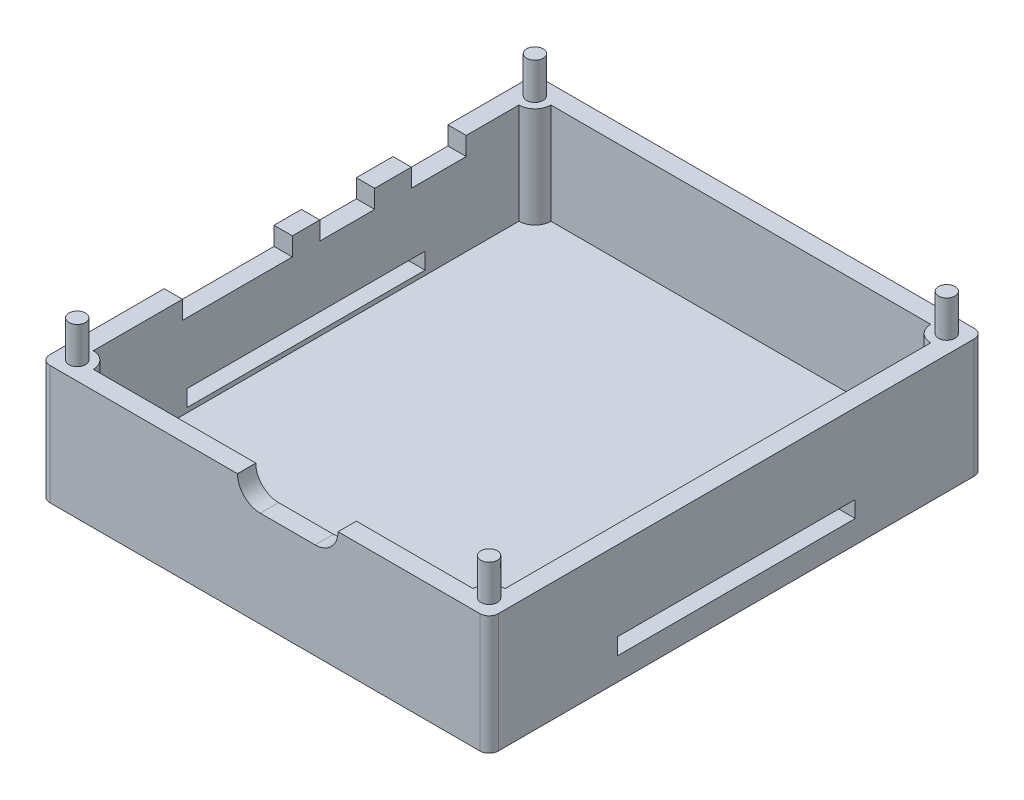
from build123d import *

# Parameters (mm, degrees)
SKETCH1_W             = 49
SKETCH1_H             = 54
BOSS_EXTRUDE1_DEPTH   = 2
SKETCH2_W             = 49
SKETCH2_H             = 54
SKETCH2_W_2           = 45
SKETCH2_H_2           = 50
EXTRUDE_THIN1_DEPTH   = 11
SKETCH7_W             = 6
SKETCH7_H             = 2
CUT_EXTRUDE1_DEPTH    = 2
SKETCH6_W             = 12
SKETCH6_H             = 2
CUT_EXTRUDE2_DEPTH    = 2
CUT_EXTRUDE3_DEPTH    = 2
SKETCH15_R            = 1.75
BOSS_EXTRUDE2_DEPTH   = 11
BOSS_EXTRUDE2_2_DEPTH = 11
BOSS_EXTRUDE2_3_DEPTH = 11
BOSS_EXTRUDE2_4_DEPTH = 11
SKETCH17_R            = 0.9
BOSS_EXTRUDE3_DEPTH   = 15
CUT_EXTRUDE4_DEPTH    = 49
FILLET1_R             = 1


with BuildPart() as part:
    # Sketch1 → Boss-Extrude1 (new body)
    with BuildSketch(Plane(origin=(0, 0, 0), x_dir=(1, 0, 0), z_dir=(0, 1, 0))):
        Rectangle(SKETCH1_W, SKETCH1_H)
    extrude(amount=BOSS_EXTRUDE1_DEPTH)

    # Sketch2 → Extrude-Thin1 (add)
    with BuildSketch(Plane(origin=(0, 2, 0), x_dir=(1, 0, 0), z_dir=(0, 1, 0))):
        Rectangle(SKETCH2_W, SKETCH2_H)
        Rectangle(SKETCH2_W_2, SKETCH2_H_2, mode=Mode.SUBTRACT)
    extrude(amount=EXTRUDE_THIN1_DEPTH)

    # Sketch7 → Cut-Extrude1 (cut)
    with BuildSketch(Plane.ZY.offset(24.5)):
        with Locations((-4.5, 12)):
            Rectangle(SKETCH7_W, SKETCH7_H)
        with Locations((-14.5, 12)):
            Rectangle(SKETCH7_W, SKETCH7_H)
    extrude(amount=-CUT_EXTRUDE1_DEPTH, mode=Mode.SUBTRACT)

    # Sketch6 → Cut-Extrude2 (cut)
    with BuildSketch(Plane.ZY.offset(24.5)):
        with Locations((7.5, 12)):
            Rectangle(SKETCH6_W, SKETCH6_H)
    extrude(amount=-CUT_EXTRUDE2_DEPTH, mode=Mode.SUBTRACT)

    # Sketch14 → Cut-Extrude3 (cut)
    with BuildSketch(Plane.XY.offset(27)):
        with BuildLine():
            Line((-0.5, 15.493238672), (5.5, 15.493238672))
            ThreePointArc((5.5, 15.493238672), (7.993238672, 13), (5.5, 10.506761328))
            Line((5.5, 10.506761328), (-0.5, 10.506761328))
            ThreePointArc((-0.5, 10.506761328), (-2.993238672, 13), (-0.5, 15.493238672))
        make_face()
    extrude(amount=-CUT_EXTRUDE3_DEPTH, mode=Mode.SUBTRACT)



with BuildPart() as body_2:
    # Sketch15 → Boss-Extrude2 (new body)
    with BuildSketch(Plane(origin=(0, 2, 0), x_dir=(1, 0, 0), z_dir=(0, 1, 0))):
        with Locations((-22.5, -25)):
            Circle(SKETCH15_R)
    extrude(amount=BOSS_EXTRUDE2_DEPTH)


with BuildPart() as body_3:
    # Sketch15 → Boss-Extrude2 2 (new body)
    with BuildSketch(Plane(origin=(0, 2, 0), x_dir=(1, 0, 0), z_dir=(0, 1, 0))):
        with Locations((-22.5, 25)):
            Circle(SKETCH15_R)
    extrude(amount=BOSS_EXTRUDE2_2_DEPTH)


with BuildPart() as body_4:
    # Sketch15 → Boss-Extrude2 3 (new body)
    with BuildSketch(Plane(origin=(0, 2, 0), x_dir=(1, 0, 0), z_dir=(0, 1, 0))):
        with Locations((22.5, 25)):
            Circle(SKETCH15_R)
    extrude(amount=BOSS_EXTRUDE2_3_DEPTH)


with BuildPart() as body_5:
    # Sketch15 → Boss-Extrude2 4 (new body)
    with BuildSketch(Plane(origin=(0, 2, 0), x_dir=(1, 0, 0), z_dir=(0, 1, 0))):
        with Locations((22.5, -25)):
            Circle(SKETCH15_R)
    extrude(amount=BOSS_EXTRUDE2_4_DEPTH)


with BuildPart() as part_1:
    add(part.part)

    add(body_2.part)  # Boss-Extrude3 merges body 2

    add(body_3.part)  # Boss-Extrude3 merges body 3

    add(body_4.part)  # Boss-Extrude3 merges body 4

    add(body_5.part)  # Boss-Extrude3 merges body 5
    # Sketch17 → Boss-Extrude3 (add)
    with BuildSketch(Plane(origin=(0, 2, 0), x_dir=(1, 0, 0), z_dir=(0, 1, 0))):
        with Locations((-22.5, -25)):
            Circle(SKETCH17_R)
        with Locations((22.5, -25)):
            Circle(SKETCH17_R)
        with Locations((22.5, 25)):
            Circle(SKETCH17_R)
        with Locations((-22.5, 25)):
            Circle(SKETCH17_R)
    extrude(amount=BOSS_EXTRUDE3_DEPTH)

    # Sketch21 → Cut-Extrude4 (cut)
    with BuildSketch(Plane.ZY.offset(24.5)):
        Polygon((0, 2.5), (-13, 2.5), (-13, 4.3), (13, 4.3), (13, 2.5), align=None)
    extrude(amount=-CUT_EXTRUDE4_DEPTH, mode=Mode.SUBTRACT)

    # Fillet1
    fillet1_edges = [part_1.edges().sort_by_distance(p)[0] for p in [
        (-24.5, 6.5, -27),
        (24.5, 6.5, -27),
        (24.5, 6.5, 27),
        (-24.5, 6.5, 27),
    ]]
    fillet(fillet1_edges, radius=FILLET1_R)


solid = part_1.part
